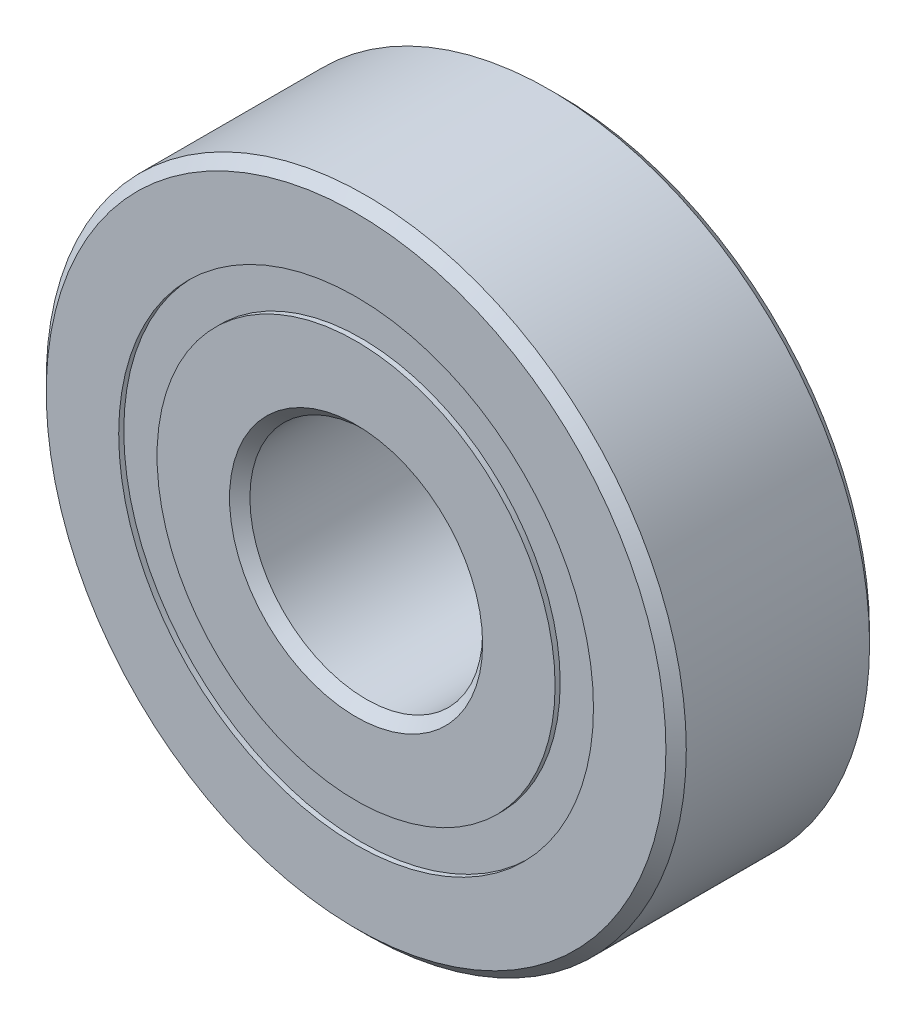
from build123d import *

# Parameters (mm, degrees)
CIRPATTERN1_COUNT = 10
SKETCH6_W         = 1.635478413
SKETCH6_H         = 1.318681318


with BuildPart() as part:
    # Sketch1 → Revolve1 (revolve)
    with BuildSketch(Plane(origin=(0, 0, 0), x_dir=(0, 0, -1), z_dir=(1, 0, 0))):
        with BuildLine():
            Line((3.15, 11), (-3.15, 11))
            Line((-3.15, 11), (-3.5, 10.65))
            Line((-3.5, 10.65), (-3.5, 8.159340659))
            Line((-3.5, 8.159340659), (-1.555555556, 8.159340659))
            ThreePointArc((-1.555555556, 8.159340659), (0, 9.189521587), (1.555555556, 8.159340659))
            Line((1.555555556, 8.159340659), (3.5, 8.159340659))
            Line((3.5, 8.159340659), (3.5, 10.65))
            Line((3.5, 10.65), (3.15, 11))
        make_face()
    revolve(axis=Axis((0, 0, 3.5), (0, 0, -1)))


with BuildPart() as body_2:
    # Sketch3 → Revolve3 (revolve)
    with BuildSketch(Plane(origin=(0, 0, 0), x_dir=(0, 0, -1), z_dir=(1, 0, 0))):
        with BuildLine():
            Line((-3.5, 6.840659341), (-1.555555556, 6.840659341))
            ThreePointArc((-1.555555556, 6.840659341), (0, 5.810478413), (1.555555556, 6.840659341))
            Line((1.555555556, 6.840659341), (3.5, 6.840659341))
            Line((3.5, 6.840659341), (3.5, 4.35))
            Line((3.5, 4.35), (3.15, 4))
            Line((3.15, 4), (-3.15, 4))
            Line((-3.15, 4), (-3.5, 4.35))
            Line((-3.5, 4.35), (-3.5, 6.840659341))
        make_face()
    revolve(axis=Axis((0, 0, 3.5), (0, 0, -1)))


with BuildPart() as body_3:
    # Sketch4 → Revolve4 (revolve)
    with BuildSketch(Plane(origin=(0, 0, 0), x_dir=(0, 0, -1), z_dir=(1, 0, 0))):
        with BuildLine():
            Line((-1.689521587, 7.5), (1.689521587, 7.5))
            ThreePointArc((1.689521587, 7.5), (0, 9.189521587), (-1.689521587, 7.5))
        make_face()
    revolve(axis=Axis((0, 7.5, 1.689521587), (0, 0, -1)))


with BuildPart() as cirpattern1_1:
    # CirPattern1: pattern copy
    add(body_3.part.rotate(Axis((0, 0, -3.5), (0, 0, 1)), 1 * 360 / CIRPATTERN1_COUNT))


with BuildPart() as cirpattern1_2:
    # CirPattern1: pattern copy
    add(body_3.part.rotate(Axis((0, 0, -3.5), (0, 0, 1)), 2 * 360 / CIRPATTERN1_COUNT))


with BuildPart() as cirpattern1_3:
    # CirPattern1: pattern copy
    add(body_3.part.rotate(Axis((0, 0, -3.5), (0, 0, 1)), 3 * 360 / CIRPATTERN1_COUNT))


with BuildPart() as cirpattern1_4:
    # CirPattern1: pattern copy
    add(body_3.part.rotate(Axis((0, 0, -3.5), (0, 0, 1)), 4 * 360 / CIRPATTERN1_COUNT))


with BuildPart() as cirpattern1_5:
    # CirPattern1: pattern copy
    add(body_3.part.rotate(Axis((0, 0, -3.5), (0, 0, 1)), 5 * 360 / CIRPATTERN1_COUNT))


with BuildPart() as cirpattern1_6:
    # CirPattern1: pattern copy
    add(body_3.part.rotate(Axis((0, 0, -3.5), (0, 0, 1)), 6 * 360 / CIRPATTERN1_COUNT))


with BuildPart() as cirpattern1_7:
    # CirPattern1: pattern copy
    add(body_3.part.rotate(Axis((0, 0, -3.5), (0, 0, 1)), 7 * 360 / CIRPATTERN1_COUNT))


with BuildPart() as cirpattern1_8:
    # CirPattern1: pattern copy
    add(body_3.part.rotate(Axis((0, 0, -3.5), (0, 0, 1)), 8 * 360 / CIRPATTERN1_COUNT))


with BuildPart() as cirpattern1_9:
    # CirPattern1: pattern copy
    add(body_3.part.rotate(Axis((0, 0, -3.5), (0, 0, 1)), 9 * 360 / CIRPATTERN1_COUNT))


with BuildPart() as body_13:
    # Sketch6 → Revolve5 (revolve)
    with BuildSketch(Plane(origin=(0, 0, 0), x_dir=(0, 0, -1), z_dir=(1, 0, 0))):
        with Locations((-2.507260794, 7.5)):
            Rectangle(SKETCH6_W, SKETCH6_H)
        with Locations((2.507260794, 7.5)):
            Rectangle(SKETCH6_W, SKETCH6_H)
    revolve(axis=Axis((0, 0, 3.5), (0, 0, -1)))


solid = Compound([part.part, body_2.part, body_3.part, cirpattern1_1.part, cirpattern1_2.part, cirpattern1_3.part, cirpattern1_4.part, cirpattern1_5.part, cirpattern1_6.part, cirpattern1_7.part, cirpattern1_8.part, cirpattern1_9.part, body_13.part])
